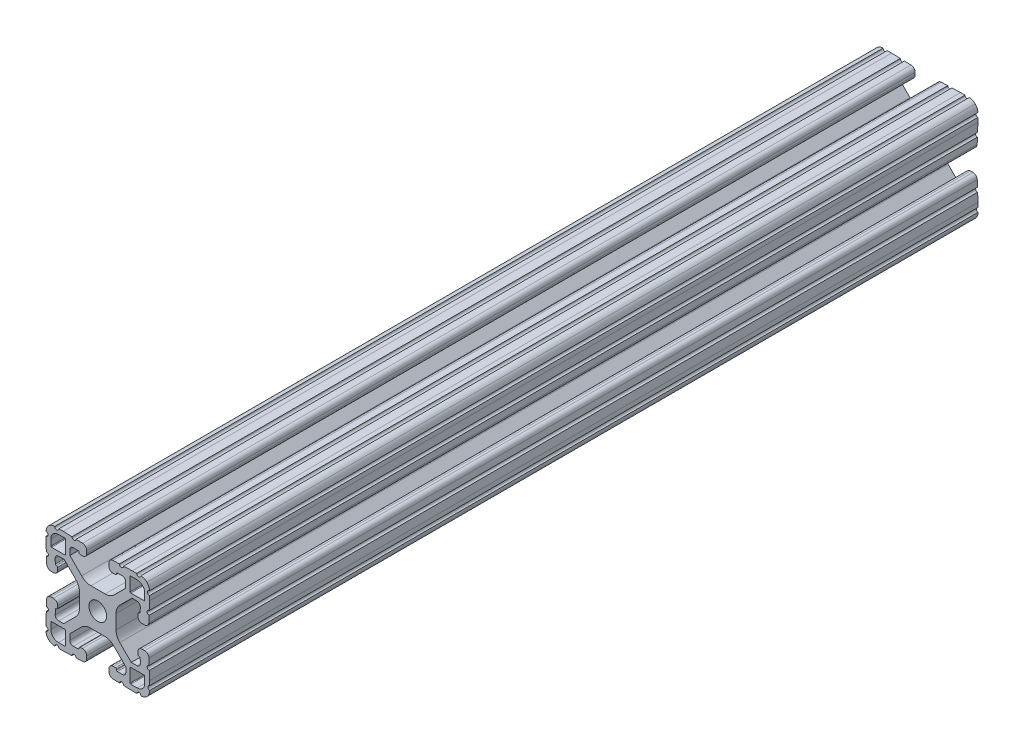
from build123d import *

# Parameters (mm, degrees)
SKETCH1_R           = 3.2639
BOSS_EXTRUDE1_DEPTH = 304.8


with BuildPart() as part:
    # Sketch1 → Boss-Extrude1 (new body)
    with BuildSketch(Plane(origin=(0, 0, -25.4), x_dir=(-1, 0, 0), z_dir=(0, 0, -1))):
        with BuildLine():
            Line((-88.043721549, 91.862643967), (-86.29674679, 91.923648859))
            ThreePointArc((-86.29674679, 91.923648859), (-85.370208675, 91.567983831), (-84.982425017, 90.654422489))
            Line((-84.982425017, 90.654422489), (-84.982425017, 88.800173916))
            Line((-84.982425017, 88.800173916), (-89.306565884, 84.476033049))
            ThreePointArc((-89.306565884, 84.476033049), (-90.866149908, 83.406077005), (-92.719610366, 83.029523439))
            Line((-92.719610366, 83.029523439), (-97.961628589, 83.029523439))
            ThreePointArc((-97.961628589, 83.029523439), (-99.779298356, 83.391080435), (-101.320244378, 84.42070765))
            Line((-101.320244378, 84.42070765), (-105.516001761, 88.616465033))
            Line((-105.516001761, 88.616465033), (-105.516001761, 90.731330035))
            ThreePointArc((-105.516001761, 90.731330035), (-105.128218103, 91.644891377), (-104.201679988, 92.000556406))
            Line((-104.201679988, 92.000556406), (-102.454705229, 91.939551513))
            ThreePointArc((-102.454705229, 91.939551513), (-102.193933359, 91.823448504), (-102.087001761, 91.558783602))
            ThreePointArc((-102.087001761, 91.558783602), (-102.010859042, 91.249291513), (-101.726191901, 91.105946874))
            Line((-101.726191901, 91.105946874), (-100.929727576, 91.078102142))
            ThreePointArc((-100.929727576, 91.078102142), (-99.780779944, 91.519102656), (-99.299905511, 92.651940638))
            Line((-99.299905511, 92.651940638), (-99.299905511, 93.566848638))
            ThreePointArc((-99.299905511, 93.566848638), (-99.741889517, 94.660796975), (-100.819746715, 95.140689345))
            Line((-100.819746715, 95.140689345), (-103.211918901, 95.224224422))
            ThreePointArc((-103.211918901, 95.224224422), (-104.000045777, 94.489281495), (-104.734990687, 95.277406522))
            Line((-104.734990687, 95.277406522), (-107.935905676, 95.389166912))
            Line((-107.935905676, 95.389166912), (-109.561454876, 95.389166912))
            ThreePointArc((-109.561454876, 95.389166912), (-110.323454876, 94.627166912), (-111.085454876, 95.389166912))
            ThreePointArc((-111.085454876, 95.389166912), (-112.308767787, 95.144035599), (-113.343184761, 94.446493225))
            ThreePointArc((-113.343184761, 94.446493225), (-114.04072548, 93.412075135), (-114.285854836, 92.188761832))
            ThreePointArc((-114.285854836, 92.188761832), (-113.523853616, 91.426762441), (-114.285853616, 90.664761832))
            Line((-114.285853616, 90.664761832), (-114.285853616, 89.039212632))
            Line((-114.285853616, 89.039212632), (-114.174093219, 85.838297643))
            ThreePointArc((-114.174093219, 85.838297643), (-113.385968191, 85.103352735), (-114.120911115, 84.315225857))
            Line((-114.120911115, 84.315225857), (-114.037376031, 81.923053667))
            ThreePointArc((-114.037376031, 81.923053667), (-113.55748366, 80.845196472), (-112.463535325, 80.403212468))
            Line((-112.463535325, 80.403212468), (-111.548627325, 80.403212468))
            ThreePointArc((-111.548627325, 80.403212468), (-110.415788905, 80.884087354), (-109.974788872, 82.033035791))
            Line((-109.974788872, 82.033035791), (-110.002634241, 82.829500094))
            ThreePointArc((-110.002634241, 82.829500094), (-110.118742417, 83.090261917), (-110.383401914, 83.197188))
            ThreePointArc((-110.383401914, 83.197188), (-110.693757401, 83.272605688), (-110.837665276, 83.557735272))
            Line((-110.837665276, 83.557735272), (-110.898671566, 85.304709982))
            ThreePointArc((-110.898671566, 85.304709982), (-110.543006925, 86.231248747), (-109.62944523, 86.61903277))
            Line((-109.62944523, 86.61903277), (-107.807161806, 86.61903277))
            Line((-107.807161806, 86.61903277), (-103.364925613, 82.176810793))
            ThreePointArc((-103.364925613, 82.176810793), (-102.335294479, 80.635862907), (-101.973736029, 78.81818963))
            Line((-101.973736029, 78.81818963), (-101.973736029, 73.576034207))
            ThreePointArc((-101.973736029, 73.576034207), (-102.335293752, 71.758362684), (-103.364922926, 70.21741573))
            Line((-103.364922926, 70.21741573), (-107.560683666, 66.021661704))
            Line((-107.560683666, 66.021661704), (-109.652436558, 66.021661704))
            ThreePointArc((-109.652436558, 66.021661704), (-110.565998503, 66.409445617), (-110.921663765, 67.335984343))
            Line((-110.921663765, 67.335984343), (-110.860658873, 69.082959102))
            ThreePointArc((-110.860658873, 69.082959102), (-110.744555864, 69.343730973), (-110.479890961, 69.45066257))
            ThreePointArc((-110.479890961, 69.45066257), (-110.173494703, 69.529390272), (-110.032185196, 69.812424443))
            Line((-110.032185196, 69.812424443), (-110.004340464, 70.608888768))
            ThreePointArc((-110.004340464, 70.608888768), (-110.445340978, 71.7578364), (-111.57817896, 72.238710833))
            Line((-111.57817896, 72.238710833), (-112.49308696, 72.238710833))
            ThreePointArc((-112.49308696, 72.238710833), (-113.587035297, 71.796726827), (-114.066927667, 70.718869629))
            Line((-114.066927667, 70.718869629), (-114.150462744, 68.326697443))
            ThreePointArc((-114.150462744, 68.326697443), (-113.415519817, 67.538570567), (-114.203644843, 66.803625657))
            Line((-114.203644843, 66.803625657), (-114.315405233, 63.602710668))
            Line((-114.315405233, 63.602710668), (-114.315405233, 61.962557497))
            ThreePointArc((-114.315405233, 61.962557497), (-113.701927281, 61.206106537), (-114.333208228, 60.464447842))
            ThreePointArc((-114.333208228, 60.464447842), (-114.113020459, 59.176546471), (-113.392816136, 58.086372941))
            ThreePointArc((-113.392816136, 58.086372941), (-112.358398046, 57.388832223), (-111.135084743, 57.143702867))
            ThreePointArc((-111.135084743, 57.143702867), (-110.373085352, 57.905704086), (-109.611084743, 57.143704086))
            Line((-109.611084743, 57.143704086), (-107.985535543, 57.143704086))
            Line((-107.985535543, 57.143704086), (-104.784620554, 57.255464483))
            ThreePointArc((-104.784620554, 57.255464483), (-104.049675645, 58.04358951), (-103.261548768, 57.308646586))
            Line((-103.261548768, 57.308646586), (-100.869376578, 57.39218167))
            ThreePointArc((-100.869376578, 57.39218167), (-99.791519383, 57.872074041), (-99.349535378, 58.966022376))
            Line((-99.349535378, 58.966022376), (-99.349535378, 59.880930376))
            ThreePointArc((-99.349535378, 59.880930376), (-99.830409811, 61.013768358), (-100.979357443, 61.454768873))
            Line((-100.979357443, 61.454768873), (-101.775821768, 61.42692414))
            ThreePointArc((-101.775821768, 61.42692414), (-102.036583684, 61.310816174), (-102.143509978, 61.046156762))
            ThreePointArc((-102.143509978, 61.046156762), (-102.222494916, 60.740061862), (-102.505377386, 60.598958297))
            Line((-102.505377386, 60.598958297), (-104.252352145, 60.537953405))
            ThreePointArc((-104.252352145, 60.537953405), (-105.17889026, 60.893618433), (-105.566673918, 61.807179775))
            Line((-105.566673918, 61.807179775), (-105.566673918, 63.629462758))
            Line((-105.566673918, 63.629462758), (-101.131142468, 68.064994208))
            ThreePointArc((-101.131142468, 68.064994208), (-99.590196446, 69.094621422), (-97.772526678, 69.456178419))
            Line((-97.772526678, 69.456178419), (-92.530356056, 69.456178419))
            ThreePointArc((-92.530356056, 69.456178419), (-90.712686289, 69.094621422), (-89.171740267, 68.064994208))
            Line((-89.171740267, 68.064994208), (-84.975982884, 63.869236825))
            Line((-84.975982884, 63.869236825), (-84.975982884, 61.781050107))
            ThreePointArc((-84.975982884, 61.781050107), (-85.363766542, 60.867488765), (-86.290304657, 60.511823736))
            Line((-86.290304657, 60.511823736), (-88.037279416, 60.572828629))
            ThreePointArc((-88.037279416, 60.572828629), (-88.298051286, 60.688931638), (-88.404982884, 60.95359654))
            ThreePointArc((-88.404982884, 60.95359654), (-88.466593694, 61.278962759), (-88.759626911, 61.433204782))
            Line((-88.759626911, 61.433204782), (-89.556091237, 61.461049514))
            ThreePointArc((-89.556091237, 61.461049514), (-90.705038868, 61.020049), (-91.185913301, 59.887211018))
            Line((-91.185913301, 59.887211018), (-91.185913301, 58.972303018))
            ThreePointArc((-91.185913301, 58.972303018), (-90.743929295, 57.878354681), (-89.666072098, 57.398462311))
            Line((-89.666072098, 57.398462311), (-87.273899911, 57.314927234))
            ThreePointArc((-87.273899911, 57.314927234), (-86.485773036, 58.049870161), (-85.750828126, 57.261745135))
            Line((-85.750828126, 57.261745135), (-82.549913136, 57.149984745))
            Line((-82.549913136, 57.149984745), (-80.924363936, 57.149984745))
            ThreePointArc((-80.924363936, 57.149984745), (-80.162363936, 57.911984745), (-79.400363936, 57.149984745))
            ThreePointArc((-79.400363936, 57.149984745), (-78.177051025, 57.395116058), (-77.142634052, 58.092658432))
            ThreePointArc((-77.142634052, 58.092658432), (-76.445094372, 59.127074031), (-76.199963977, 60.350384428))
            ThreePointArc((-76.199963977, 60.350384428), (-76.961961268, 61.112385783), (-76.199961268, 61.874384428))
            Line((-76.199961268, 61.874384428), (-76.199961268, 63.499933628))
            Line((-76.199961268, 63.499933628), (-76.311721666, 66.700848617))
            ThreePointArc((-76.311721666, 66.700848617), (-77.099846694, 67.435793525), (-76.364903769, 68.223920403))
            Line((-76.364903769, 68.223920403), (-76.448438853, 70.616092593))
            ThreePointArc((-76.448438853, 70.616092593), (-76.928331225, 71.693949788), (-78.02227956, 72.135933792))
            Line((-78.02227956, 72.135933792), (-78.93718756, 72.135933792))
            ThreePointArc((-78.93718756, 72.135933792), (-80.07002598, 71.655058906), (-80.511026012, 70.506110469))
            Line((-80.511026012, 70.506110469), (-80.483180643, 69.709646166))
            ThreePointArc((-80.483180643, 69.709646166), (-80.367072468, 69.448884343), (-80.102412971, 69.34195826))
            ThreePointArc((-80.102412971, 69.34195826), (-79.796317908, 69.262973649), (-79.655214052, 68.980091239))
            Line((-79.655214052, 68.980091239), (-79.594207761, 67.233116529))
            ThreePointArc((-79.594207761, 67.233116529), (-79.949872402, 66.306577764), (-80.863434097, 65.918793741))
            Line((-80.863434097, 65.918793741), (-82.685717521, 65.918793741))
            Line((-82.685717521, 65.918793741), (-87.121258001, 70.35431293))
            ThreePointArc((-87.121258001, 70.35431293), (-88.150863946, 71.895196205), (-88.512450271, 73.712794894))
            Line((-88.512450271, 73.712794894), (-88.512606864, 78.954950317))
            ThreePointArc((-88.512606864, 78.954950317), (-88.151076291, 80.772698182), (-87.121419968, 82.313710679))
            Line((-87.121419968, 82.313710679), (-82.925659228, 86.509464706))
            Line((-82.925659228, 86.509464706), (-80.837473527, 86.509464706))
            ThreePointArc((-80.837473527, 86.509464706), (-79.923911584, 86.121680793), (-79.568246321, 85.195142068))
            Line((-79.568246321, 85.195142068), (-79.629251214, 83.448167309))
            ThreePointArc((-79.629251214, 83.448167309), (-79.745354223, 83.187395438), (-80.010019125, 83.080463841))
            ThreePointArc((-80.010019125, 83.080463841), (-80.335385344, 83.018853031), (-80.489627367, 82.725819813))
            Line((-80.489627367, 82.725819813), (-80.5174721, 81.929355488))
            ThreePointArc((-80.5174721, 81.929355488), (-80.076471586, 80.780407856), (-78.943633603, 80.299533423))
            Line((-78.943633603, 80.299533423), (-78.028725603, 80.299533423))
            ThreePointArc((-78.028725603, 80.299533423), (-76.934777267, 80.741517429), (-76.454884897, 81.819374627))
            Line((-76.454884897, 81.819374627), (-76.37134982, 84.211546813))
            ThreePointArc((-76.37134982, 84.211546813), (-77.106292747, 84.999673689), (-76.31816772, 85.734618599))
            Line((-76.31816772, 85.734618599), (-76.20640733, 88.935533588))
            Line((-76.20640733, 88.935533588), (-76.20640733, 90.561082788))
            ThreePointArc((-76.20640733, 90.561082788), (-76.96840733, 91.323083398), (-76.206406111, 92.085082788))
            ThreePointArc((-76.206406111, 92.085082788), (-76.451535467, 93.308396091), (-77.149076185, 94.342814181))
            ThreePointArc((-77.149076185, 94.342814181), (-78.183493159, 95.040356555), (-79.40680607, 95.285487868))
            ThreePointArc((-79.40680607, 95.285487868), (-80.16880607, 94.523487868), (-80.93080607, 95.285487868))
            Line((-80.93080607, 95.285487868), (-82.55635527, 95.285487868))
            Line((-82.55635527, 95.285487868), (-85.757270259, 95.173727471))
            ThreePointArc((-85.757270259, 95.173727471), (-86.492215168, 94.385602444), (-87.280342045, 95.120545368))
            Line((-87.280342045, 95.120545368), (-89.672514235, 95.037010285))
            ThreePointArc((-89.672514235, 95.037010285), (-90.75037143, 94.557117913), (-91.192355435, 93.463169578))
            Line((-91.192355435, 93.463169578), (-91.192355435, 92.548261578))
            ThreePointArc((-91.192355435, 92.548261578), (-90.711481002, 91.415423596), (-89.56253337, 90.974423082))
            Line((-89.56253337, 90.974423082), (-88.766069045, 91.002267814))
            ThreePointArc((-88.766069045, 91.002267814), (-88.505307129, 91.11837578), (-88.398380835, 91.383035192))
            ThreePointArc((-88.398380835, 91.383035192), (-88.336765486, 91.708407548), (-88.043721549, 91.862643967))
        make_face()
        with Locations(Location((-95.25, 76.2, 0), (0, 0, 180))):  # turned: the seam where the file's is
            Circle(SKETCH1_R, mode=Mode.SUBTRACT)
        with BuildLine():
            Line((-83.357745393, 88.294108398), (-83.357745393, 93.170908398))
            ThreePointArc((-83.357745393, 93.170908398), (-83.283351492, 93.350512545), (-83.103748154, 93.424908398))
            Line((-83.103748154, 93.424908398), (-80.766975763, 93.424933798))
            ThreePointArc((-80.766975763, 93.424933798), (-78.791299784, 92.606600882), (-77.972945393, 90.630933798))
            Line((-77.972945393, 90.630933798), (-77.972945393, 88.294108398))
            ThreePointArc((-77.972945393, 88.294108398), (-78.047340271, 88.114503276), (-78.226945393, 88.040108398))
            Line((-78.226945393, 88.040108398), (-83.103745393, 88.040108398))
            ThreePointArc((-83.103745393, 88.040108398), (-83.283350516, 88.114503276), (-83.357745393, 88.294108398))
        make_face(mode=Mode.SUBTRACT)
        with BuildLine():
            Line((-83.357745393, 59.229091602), (-83.357745393, 64.105891602))
            ThreePointArc((-83.357745393, 64.105891602), (-83.283350516, 64.285496724), (-83.103745393, 64.359891602))
            Line((-83.103745393, 64.359891602), (-78.226945393, 64.359891602))
            ThreePointArc((-78.226945393, 64.359891602), (-78.047340271, 64.285496724), (-77.972945393, 64.105891602))
            Line((-77.972945393, 64.105891602), (-77.972945393, 61.769066202))
            ThreePointArc((-77.972945393, 61.769066202), (-78.791299784, 59.793399118), (-80.766975763, 58.975066202))
            Line((-80.766975763, 58.975066202), (-83.103748154, 58.975091602))
            ThreePointArc((-83.103748154, 58.975091602), (-83.283351492, 59.049487455), (-83.357745393, 59.229091602))
        make_face(mode=Mode.SUBTRACT)
        with BuildLine():
            Line((-107.142254607, 93.170908398), (-107.142254607, 88.294108398))
            ThreePointArc((-107.142254607, 88.294108398), (-107.216649484, 88.114503276), (-107.396254607, 88.040108398))
            Line((-107.396254607, 88.040108398), (-112.273054607, 88.040108398))
            ThreePointArc((-112.273054607, 88.040108398), (-112.452659729, 88.114503276), (-112.527054607, 88.294108398))
            Line((-112.527054607, 88.294108398), (-112.527054607, 90.630933798))
            ThreePointArc((-112.527054607, 90.630933798), (-111.708700216, 92.606600882), (-109.733024237, 93.424933798))
            Line((-109.733024237, 93.424933798), (-107.396251846, 93.424908398))
            ThreePointArc((-107.396251846, 93.424908398), (-107.216648508, 93.350512545), (-107.142254607, 93.170908398))
        make_face(mode=Mode.SUBTRACT)
        with BuildLine():
            Line((-107.142254607, 64.105891602), (-107.142254607, 59.229091602))
            ThreePointArc((-107.142254607, 59.229091602), (-107.216648508, 59.049487455), (-107.396251846, 58.975091602))
            Line((-107.396251846, 58.975091602), (-109.733024237, 58.975066202))
            ThreePointArc((-109.733024237, 58.975066202), (-111.708700216, 59.793399118), (-112.527054607, 61.769066202))
            Line((-112.527054607, 61.769066202), (-112.527054607, 64.105891602))
            ThreePointArc((-112.527054607, 64.105891602), (-112.452659729, 64.285496724), (-112.273054607, 64.359891602))
            Line((-112.273054607, 64.359891602), (-107.396254607, 64.359891602))
            ThreePointArc((-107.396254607, 64.359891602), (-107.216649484, 64.285496724), (-107.142254607, 64.105891602))
        make_face(mode=Mode.SUBTRACT)
    extrude(amount=-BOSS_EXTRUDE1_DEPTH)


solid = part.part
